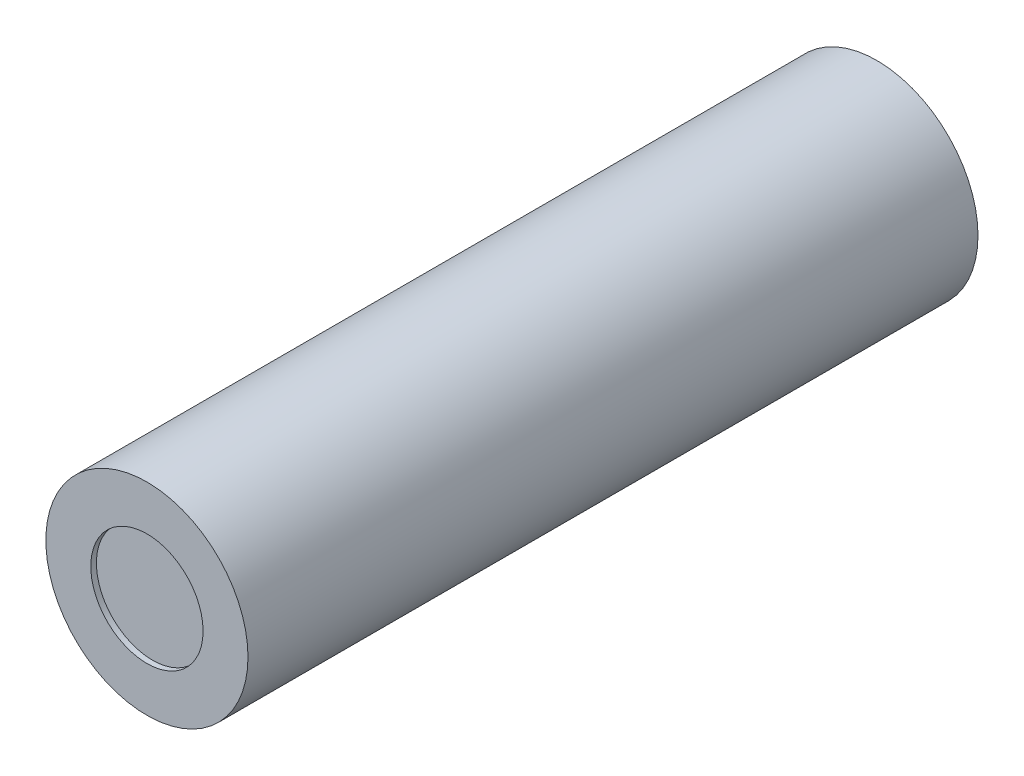
from build123d import *

# Parameters (mm, degrees)
SKETCH1_R           = 9
BOSS_EXTRUDE1_DEPTH = 65
SKETCH2_R           = 7
CUT_EXTRUDE1_DEPTH  = 0.5
SKETCH3_R           = 5
CUT_EXTRUDE3_DEPTH  = 0.5


with BuildPart() as part:
    # Sketch1 → Boss-Extrude1 (new body)
    with BuildSketch(Plane.XY):
        Circle(SKETCH1_R)
    extrude(amount=BOSS_EXTRUDE1_DEPTH)

    # Sketch2 → Cut-Extrude1 (cut)
    with BuildSketch(Plane.XY):
        Circle(SKETCH2_R)
    extrude(amount=CUT_EXTRUDE1_DEPTH, mode=Mode.SUBTRACT)

    # Sketch3 → Cut-Extrude3 (cut)
    with BuildSketch(Plane.XY.offset(65)):
        Circle(SKETCH3_R)
    extrude(amount=-CUT_EXTRUDE3_DEPTH, mode=Mode.SUBTRACT)


solid = part.part
